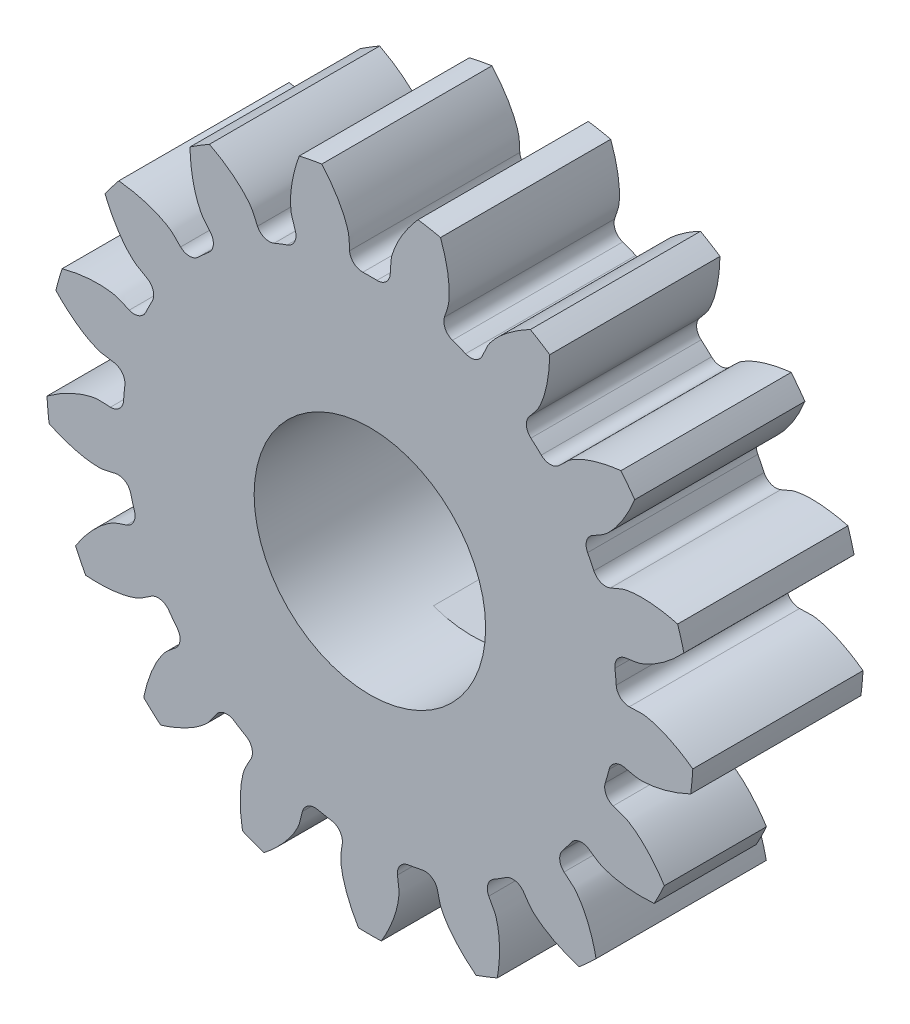
from build123d import *

# Parameters (mm, degrees)
SKETCH_1_R          = 9.5
LASHENA_DEPTH       = 5
CUT_EXTRUDEA_DEPTH  = 30
WWW_KYTOOL_CN_COUNT = 17
CUT_EXTRUDE_START   = -2
CUT_EXTRUDE_2_DEPTH = 2.000001
SKETCH_4_R          = 3.4
CUT_EXTRUDE_3_DEPTH = 4.0000001


with BuildPart() as part:
    # 草图1 → LaShenA (new body)
    with BuildSketch(Plane.XY):
        Circle(SKETCH_1_R)
    extrude(amount=LASHENA_DEPTH)

    # SketchA → Cut-ExtrudeA (cut)
    with BuildSketch(Plane.XY.offset(5)):
        with BuildLine():
            ThreePointArc((0.207024597, 7.247043591), (0, 7.25), (-0.207024597, 7.247043591))
            ThreePointArc((-0.207024597, 7.247043591), (-0.472242082, 7.34458089), (-0.596793745, 7.59823562))
            add(Edge.make_bspline(
                [(-0.596793745, 7.59823562), (-0.606044253, 7.720567809), (-0.602564219, 7.869795024), (-0.629607947, 8.02899806), (-0.642220103, 8.080828168), (-0.653298413, 8.121829162), (-0.66746571, 8.16874208), (-0.685015757, 8.221435372), (-0.706306024, 8.279743397), (-0.731664706, 8.343492078), (-0.761420108, 8.412490908), (-0.795890592, 8.486535833), (-0.835386998, 8.565408724), (-0.880211198, 8.648877936), (-0.930655859, 8.736698559), (-0.987003843, 8.828612781), (-1.049527739, 8.924350251), (-1.118489374, 9.023628457), (-1.194139339, 9.126153124), (-1.276716542, 9.23161863), (-1.36644775, 9.339708439), (-1.463547201, 9.450095543), (-1.568216064, 9.562442937), (-1.721177274, 9.717492078), (-1.84330532, 9.830913041), (-1.928368213, 9.905667778)],
                knots=[0.121183801, 0.121183801, 0.121183801, 0.121183801, 0.238205786, 0.264316947, 0.275811996, 0.289397053, 0.305072119, 0.322837193, 0.342692276, 0.364637367, 0.388672467, 0.414797575, 0.443012693, 0.473317818, 0.505712953, 0.540198096, 0.576773247, 0.615438407, 0.656193576, 0.699038754, 0.74397394, 0.790999135, 0.840114338, 0.89131955, 1, 1, 1, 1], degree=3))
            ThreePointArc((-1.928368213, 9.905667778), (0, 10.091623165), (1.928368213, 9.905667778))
            add(Edge.make_bspline(
                [(0.596793745, 7.59823562), (0.606044253, 7.720567809), (0.602564219, 7.869795024), (0.629607947, 8.02899806), (0.642220103, 8.080828168), (0.653298413, 8.121829162), (0.66746571, 8.16874208), (0.685015757, 8.221435372), (0.706306024, 8.279743397), (0.731664706, 8.343492078), (0.761420108, 8.412490908), (0.795890592, 8.486535833), (0.835386998, 8.565408724), (0.880211198, 8.648877936), (0.930655859, 8.736698559), (0.987003843, 8.828612781), (1.049527739, 8.924350251), (1.118489374, 9.023628457), (1.194139339, 9.126153124), (1.276716542, 9.23161863), (1.36644775, 9.339708439), (1.463547201, 9.450095543), (1.568216064, 9.562442937), (1.721177274, 9.717492078), (1.84330532, 9.830913041), (1.928368213, 9.905667778)],
                knots=[0.121183801, 0.121183801, 0.121183801, 0.121183801, 0.238205786, 0.264316947, 0.275811996, 0.289397053, 0.305072119, 0.322837193, 0.342692276, 0.364637367, 0.388672467, 0.414797575, 0.443012693, 0.473317818, 0.505712953, 0.540198096, 0.576773247, 0.615438407, 0.656193576, 0.699038754, 0.74397394, 0.790999135, 0.840114338, 0.89131955, 1, 1, 1, 1], degree=3))
            ThreePointArc((0.596793745, 7.59823562), (0.472242082, 7.34458089), (0.207024597, 7.247043591))
        make_face()
    cut_extrudea = extrude(amount=-CUT_EXTRUDEA_DEPTH, mode=Mode.SUBTRACT)

    # www.KYTool.cn: Cut-ExtrudeA ×17 about axis
    www_kytool_cn_axis = Axis((0, 0, -88.99), (0, 0, 1))
    for i in range(1, WWW_KYTOOL_CN_COUNT):
        add(cut_extrudea.rotate(www_kytool_cn_axis, i * 360 / WWW_KYTOOL_CN_COUNT), mode=Mode.SUBTRACT)

    # 草图3 → 切除-拉伸2 (cut)
    with BuildSketch(Plane(origin=(0, 0, 0), x_dir=(-1, 0, 0), z_dir=(0, 0, -1)).offset(CUT_EXTRUDE_START)):
        with BuildLine():
            Line((-13.594251642, -8.425931539), (1.135923205, -3.204633906))
            ThreePointArc((1.135923205, -3.204633906), (3.081446476, 1.43690209), (-1.724734634, 2.930066628))
            Line((-1.724734634, 2.930066628), (-15.192854552, -4.997716535))
            ThreePointArc((-15.192854552, -4.997716535), (-15.951017052, -7.438081407), (-13.594251642, -8.425931539))
        make_face()
    extrude(amount=CUT_EXTRUDE_2_DEPTH, mode=Mode.SUBTRACT)

    # 草图4 → 切除-拉伸3 (cut, through all)
    with BuildSketch(Plane(origin=(0, 0, 2), x_dir=(-1, 0, 0), z_dir=(0, 0, -1))):
        Circle(SKETCH_4_R)
    extrude(amount=-CUT_EXTRUDE_3_DEPTH, mode=Mode.SUBTRACT)


solid = part.part
